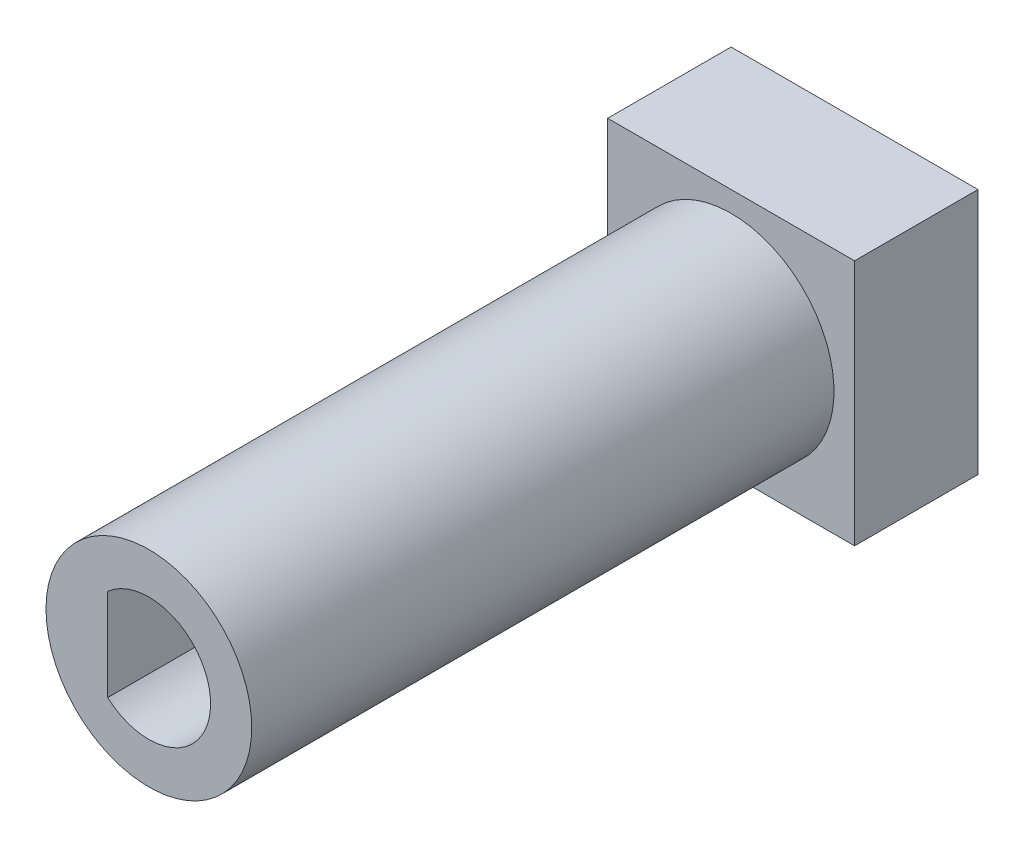
from build123d import *

# Parameters (mm, degrees)
SKETCH1_W           = 12
SKETCH1_H           = 12
BOSS_EXTRUDE1_DEPTH = 6
SKETCH2_R           = 5
BOSS_EXTRUDE2_DEPTH = 10
SKETCH3_R           = 5
BOSS_EXTRUDE3_DEPTH = 18.3
CUT_EXTRUDE2_DEPTH  = 22
SKETCH6_R           = 4
CUT_EXTRUDE3_DEPTH  = 6


with BuildPart() as part:
    # Sketch1 → Boss-Extrude1 (new body)
    with BuildSketch(Plane.XY):
        Rectangle(SKETCH1_W, SKETCH1_H)
    extrude(amount=BOSS_EXTRUDE1_DEPTH)

    # Sketch2 → Boss-Extrude2 (add)
    with BuildSketch(Plane.XY.offset(6)):
        Circle(SKETCH2_R)
    extrude(amount=BOSS_EXTRUDE2_DEPTH)

    # Sketch3 → Boss-Extrude3 (add)
    with BuildSketch(Plane.XY.offset(16)):
        Circle(SKETCH3_R)
    extrude(amount=BOSS_EXTRUDE3_DEPTH)

    # Sketch5 → Cut-Extrude2 (cut)
    with BuildSketch(Plane.XY.offset(34.3)):
        with BuildLine():
            Line((-2, 2.236067977), (-2, -2.236067977))
            ThreePointArc((-2, -2.236067977), (3, 0), (-2, 2.236067977))
        make_face()
    extrude(amount=-CUT_EXTRUDE2_DEPTH, mode=Mode.SUBTRACT)

    # Sketch6 → Cut-Extrude3 (cut)
    with BuildSketch(Plane(origin=(0, 0, 0), x_dir=(-1, 0, 0), z_dir=(0, 0, -1))):
        Circle(SKETCH6_R)
    extrude(amount=-CUT_EXTRUDE3_DEPTH, mode=Mode.SUBTRACT)


solid = part.part
